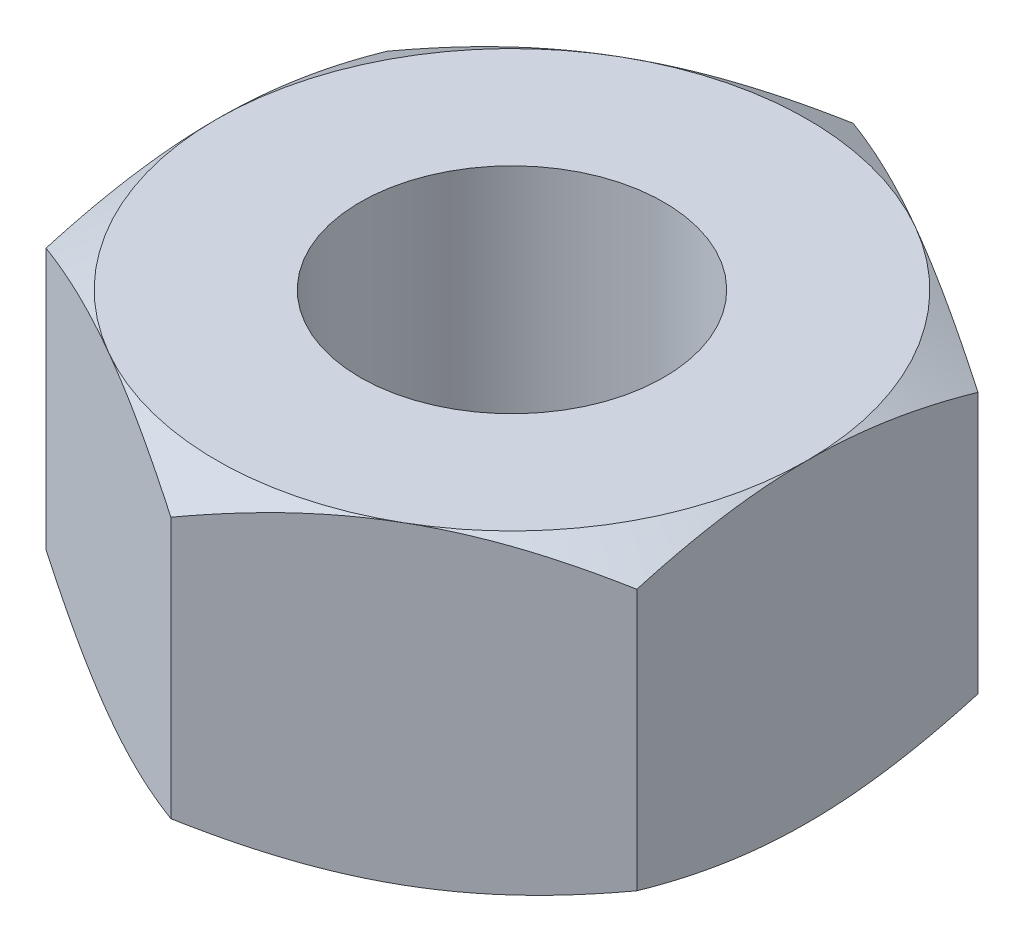
from build123d import *

# Parameters (mm, degrees)
BOSS_EXTRUDE1_DEPTH      = 3.3734375
BOSS_EXTRUDE1_DEPTH_BACK = 3.3734375
SKETCH2_OUTSIDE_W        = 45.644
SKETCH2_OUTSIDE_H        = 47.608
SKETCH2_OUTSIDE_R        = 6.35
CUT_EXTRUDE1_DEPTH       = 7.746875
CUT_EXTRUDE1_TAPER       = 60
F_5_16_18_TAPPED_HOLE1_D = 6.5278


with BuildPart() as part:
    # Sketch1 → Boss-Extrude1 (new body, two sides)
    with BuildSketch(Plane(origin=(0, 0, 0), x_dir=(1, 0, 0), z_dir=(0, 1, 0))) as boss_extrude1_sk:
        Polygon((6.35, -3.666174209), (6.35, 3.666174209), (0, 7.332348419), (-6.35, 3.666174209), (-6.35, -3.666174209), (0, -7.332348419), align=None)
    extrude(amount=BOSS_EXTRUDE1_DEPTH)
    extrude(boss_extrude1_sk.sketch, amount=-BOSS_EXTRUDE1_DEPTH_BACK)

    # Sketch2 outside → Cut-Extrude1 (cut, through all)
    with BuildSketch(Plane(origin=(0, 3.3734375, 0), x_dir=(1, 0, 0), z_dir=(0, 1, 0))):
        Rectangle(SKETCH2_OUTSIDE_W, SKETCH2_OUTSIDE_H)
        Circle(SKETCH2_OUTSIDE_R, mode=Mode.SUBTRACT)
    cut_extrude1 = extrude(amount=-CUT_EXTRUDE1_DEPTH, taper=CUT_EXTRUDE1_TAPER, mode=Mode.SUBTRACT)

    # Mirror1: Cut-Extrude1 across plane
    add(cut_extrude1.mirror(Plane.ZX), mode=Mode.SUBTRACT)

    # 5/16-18 Tapped Hole1 (through all)
    with Locations(Plane(origin=(0, 3.3734375, 0), x_dir=(1, 0, 0), z_dir=(0, 1, 0))):
        with Locations((0, 0)):
            Hole(F_5_16_18_TAPPED_HOLE1_D / 2)


solid = part.part
